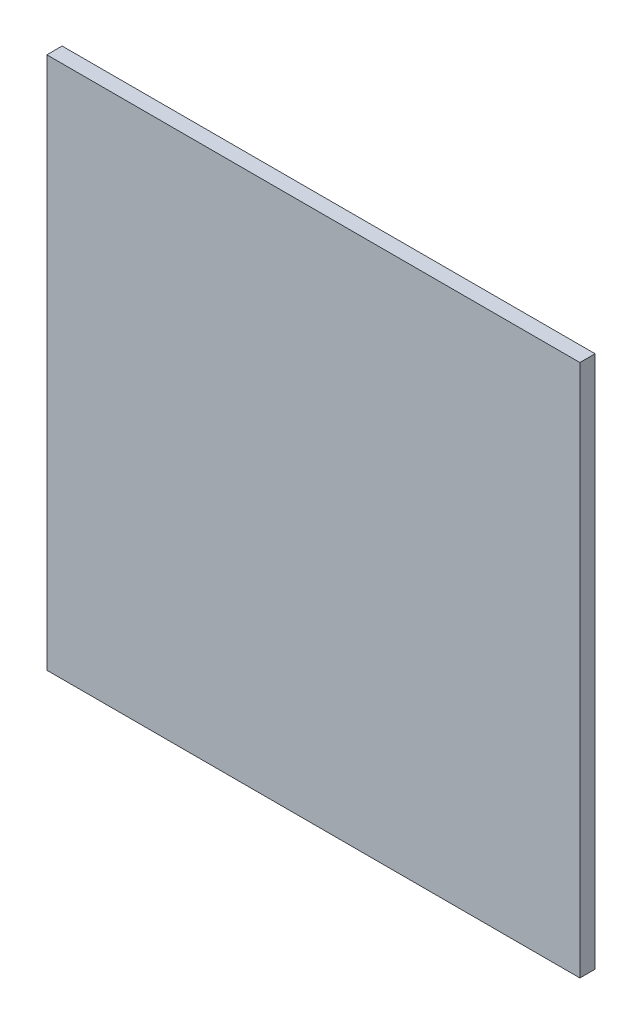
from build123d import *

# Parameters (mm, degrees)
ESQUISSE1_W        = 35
ESQUISSE1_H        = 35
BOSS_EXTRU_1_DEPTH = 1
ESQUISSE2_R        = 1
BOSS_EXTRU_2_DEPTH = 3
CHANFREIN1_SIZE    = 0.5


with BuildPart() as part:
    # Esquisse1 → Boss.-Extru.1 (new body)
    with BuildSketch(Plane.XY):
        with Locations((17.5, -17.5)):
            Rectangle(ESQUISSE1_W, ESQUISSE1_H)
    extrude(amount=BOSS_EXTRU_1_DEPTH)

    # Esquisse2 → Boss.-Extru.2 (add)
    with BuildSketch(Plane(origin=(0, 0, 0), x_dir=(-1, 0, 0), z_dir=(0, 0, -1))):
        with Locations(Location((-30, -17.5, 0), (0, 0, 180))):  # turned: the seam where the file's is
            Circle(ESQUISSE2_R)
        with Locations(Location((-5, -17.5, 0), (0, 0, 180))):  # turned: the seam where the file's is
            Circle(ESQUISSE2_R)
    extrude(amount=BOSS_EXTRU_2_DEPTH)

    # Chanfrein1
    chanfrein1_edges = [part.edges().sort_by_distance(p)[0] for p in [
        (29, -17.5, -3),
        (4, -17.5, -3),
    ]]
    chamfer(chanfrein1_edges, length=CHANFREIN1_SIZE)


solid = part.part
